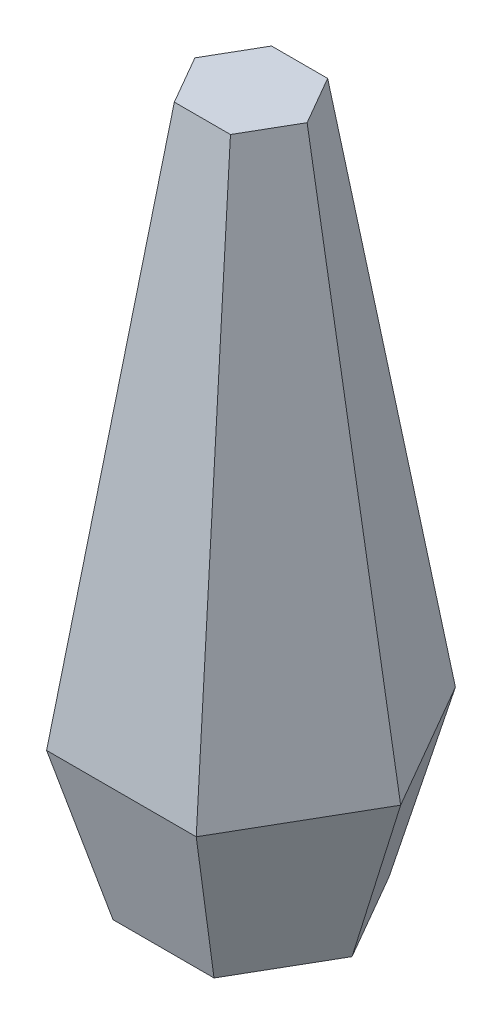
from build123d import *


with BuildPart() as part:
    # Sketch1 → Loft6 section 0
    with BuildSketch(Plane(origin=(0, 0, 0), x_dir=(1, 0, 0), z_dir=(0, 1, 0))):
        with BuildLine():
            Line((395.94681461, 0), (197.973407305, 342.9))
            Line((197.973407305, 342.9), (-197.973407305, 342.9))
            Line((-197.973407305, 342.9), (-395.94681461, 0))
            Line((-395.94681461, 0), (-197.973407305, -342.9))
            Line((-197.973407305, -342.9), (197.973407305, -342.9))
            Line((197.973407305, -342.9), (395.94681461, 0))
        make_face()
    # Sketch3 → Loft6 section 1
    with BuildSketch(Plane(origin=(0, 609.6, 0), x_dir=(-1, 0, 0), z_dir=(0, 1, 0))):
        with BuildLine():
            Line((-586.587873497, 0), (-293.293936748, -508))
            Line((-293.293936748, -508), (293.293936748, -508))
            Line((293.293936748, -508), (586.587873497, 0))
            Line((586.587873497, 0), (293.293936748, 508))
            Line((293.293936748, 508), (-293.293936748, 508))
            Line((-293.293936748, 508), (-586.587873497, 0))
        make_face()
    loft()

    # Sketch3_4 → Loft7 section 0
    with BuildSketch(Plane(origin=(0, 609.6, 0), x_dir=(-1, 0, 0), z_dir=(0, 1, 0))):
        with BuildLine():
            Line((-586.587873497, 0), (-293.293936748, -508))
            Line((-293.293936748, -508), (293.293936748, -508))
            Line((293.293936748, -508), (586.587873497, 0))
            Line((586.587873497, 0), (293.293936748, 508))
            Line((293.293936748, 508), (-293.293936748, 508))
            Line((-293.293936748, 508), (-586.587873497, 0))
        make_face()
    # Sketch4 → Loft7 section 1
    with BuildSketch(Plane(origin=(0, 2743.2, 0), x_dir=(-1, 0, 0), z_dir=(0, 1, 0))):
        with BuildLine():
            Line((219.970452561, 0), (109.985226281, 190.5))
            Line((109.985226281, 190.5), (-109.985226281, 190.5))
            Line((-109.985226281, 190.5), (-219.970452561, 0))
            Line((-219.970452561, 0), (-109.985226281, -190.5))
            Line((-109.985226281, -190.5), (109.985226281, -190.5))
            Line((109.985226281, -190.5), (219.970452561, 0))
        make_face()
    loft()


solid = part.part
